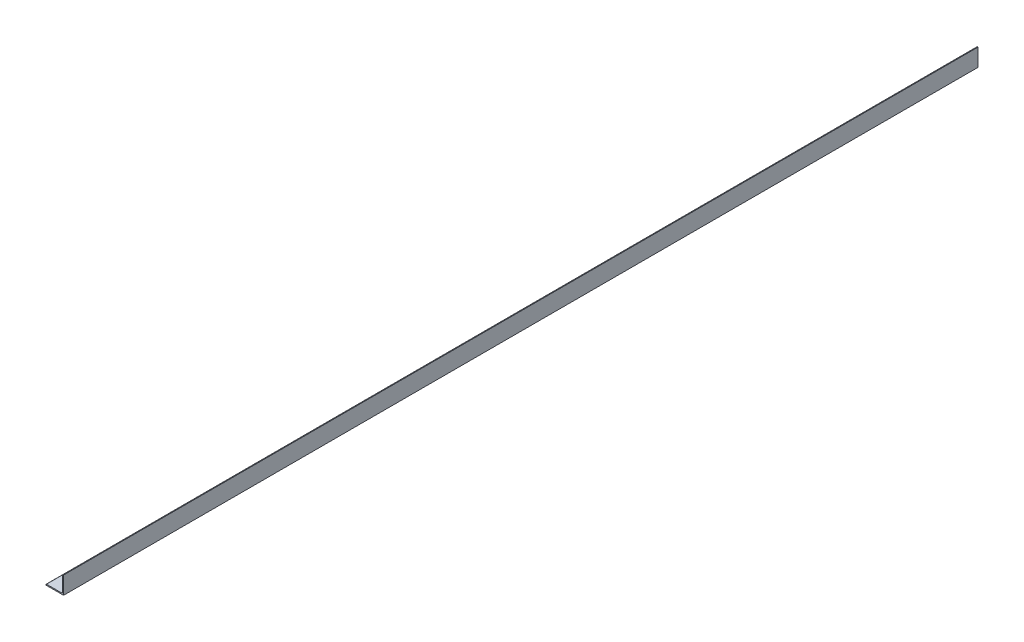
from build123d import *

# Parameters (mm, degrees)
BOSS_EXTRUDE1_DEPTH = 660.4


with BuildPart() as part:
    # Sketch2 → Boss-Extrude1 (new body, symmetric)
    with BuildSketch(Plane.XY):
        with BuildLine():
            Line((-12.7, -12.7), (12.7, -12.7))
            Line((12.7, -12.7), (12.7, 12.7))
            Line((12.7, 12.7), (11.90625, 12.7))
            ThreePointArc((11.90625, 12.7), (11.344983992, 12.467516008), (11.1125, 11.90625))
            Line((11.1125, 11.90625), (11.1125, -9.5377))
            ThreePointArc((11.1125, -9.5377), (10.651251759, -10.651251759), (9.5377, -11.1125))
            Line((9.5377, -11.1125), (-11.90625, -11.1125))
            ThreePointArc((-11.90625, -11.1125), (-12.467516008, -11.344983992), (-12.7, -11.90625))
            Line((-12.7, -11.90625), (-12.7, -12.7))
        make_face()
    extrude(amount=BOSS_EXTRUDE1_DEPTH, both=True)


solid = part.part
